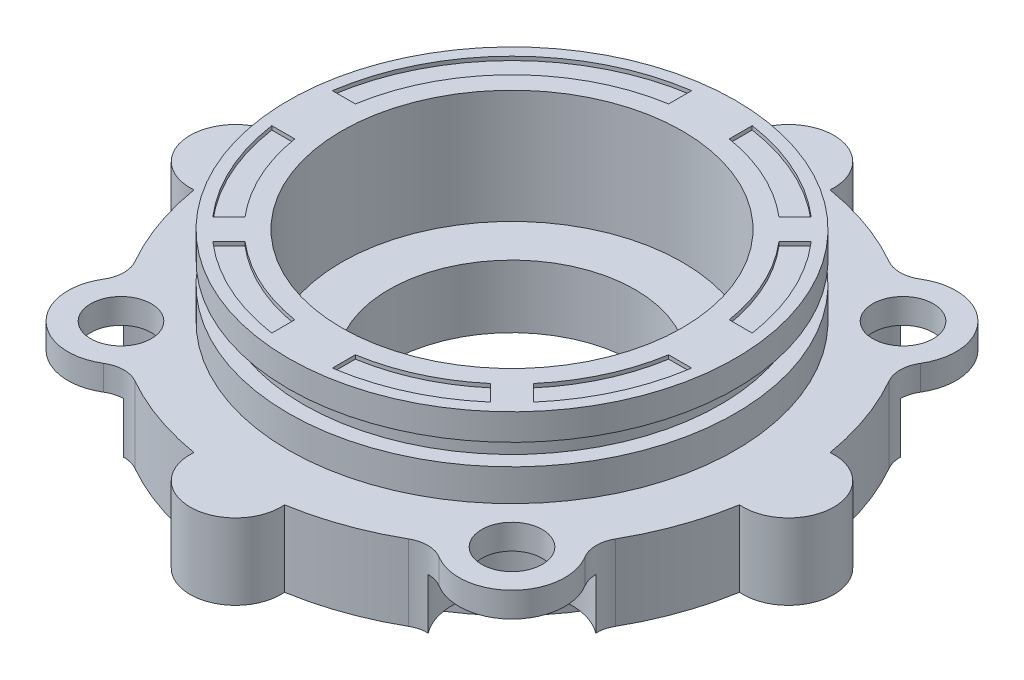
from build123d import *

# Parameters (mm, degrees)
CUT_EXTRUDE2_DEPTH = 65.844043674
SKETCH4_R          = 4
CUT_EXTRUDE3_DEPTH = 6.7
SKETCH5_R          = 4
CUT_EXTRUDE4_DEPTH = 36.7
CIRPATTERN1_COUNT  = 4
CUT_EXTRUDE5_START = -0.5
SKETCH6_R          = 22.5
CUT_EXTRUDE5_DEPTH = 0.5


with BuildPart() as part:
    # Sketch1 → Revolve1 (revolve)
    with BuildSketch(Plane.XY):
        Polygon((16.25, -33.807578124), (29.5, -33.807578124), (29.5, -31.007578124), (43.5, -31.007578124), (43.5, -21.007578124), (29.5, -21.007578124), (29.5, -16.800812474), (27.5, -16.800812474), (27.5, -14.000812474), (29.5, -14.000812474), (29.5, -10.507578124), (22.5, -10.507578124), (22.5, -25.507578124), (16.25, -25.507578124), align=None)
    revolve(axis=Axis((0, 0, 0), (0, -1, 0)))

    # Sketch2 → Cut-Extrude2 (cut, through all)
    with BuildSketch(Plane.XZ.offset(31.007578124)):
        with BuildLine():
            ThreePointArc((-18.075547766, 31.710007458), (-12.217996522, 34.394339083), (-5.97969919, 36.006849315))
            ThreePointArc((-5.97969919, 36.006849315), (0, 42.5), (5.97969919, 36.006849315))
            ThreePointArc((5.97969919, 36.006849315), (12.217996522, 34.394339083), (18.075547766, 31.710007458))
            ThreePointArc((18.075547766, 31.710007458), (20.120976666, 31.185597591), (22.148418004, 31.775738857))
            ThreePointArc((22.148418004, 31.775738857), (26.630126737, 32.76111698), (30.759144954, 30.759145009))
            ThreePointArc((30.759144954, 30.759145009), (-2.4e-08, 43.5), (-30.759144987, 30.759144976))
            ThreePointArc((-30.759144987, 30.759144976), (-26.63012676, 32.761116977), (-22.148418004, 31.775738857))
            ThreePointArc((-22.148418004, 31.775738857), (-20.120976666, 31.185597591), (-18.075547766, 31.710007458))
        make_face()
        with BuildLine():
            ThreePointArc((-31.775738857, 22.148418004), (-32.761116978, 26.630126752), (-30.759144987, 30.759144976))
            ThreePointArc((-30.759144987, 30.759144976), (-43.5, -2.1e-08), (-30.759144958, -30.759145005))
            ThreePointArc((-30.759144958, -30.759145005), (-32.761116976, -26.630126773), (-31.775738857, -22.148418004))
            ThreePointArc((-31.775738857, -22.148418004), (-31.185597591, -20.120976666), (-31.710007458, -18.075547766))
            ThreePointArc((-31.710007458, -18.075547766), (-34.394339083, -12.217996522), (-36.006849315, -5.97969919))
            ThreePointArc((-36.006849315, -5.97969919), (-42.5, 0), (-36.006849315, 5.97969919))
            ThreePointArc((-36.006849315, 5.97969919), (-34.394339083, 12.217996522), (-31.710007458, 18.075547766))
            ThreePointArc((-31.710007458, 18.075547766), (-31.185597591, 20.120976666), (-31.775738857, 22.148418004))
        make_face()
        with BuildLine():
            ThreePointArc((30.759144986, -30.759144977), (43.5, 2.3e-08), (30.759144954, 30.759145009))
            ThreePointArc((30.759144954, 30.759145009), (32.761116975, 26.630126776), (31.775738857, 22.148418004))
            ThreePointArc((31.775738857, 22.148418004), (31.185597591, 20.120976666), (31.710007458, 18.075547766))
            ThreePointArc((31.710007458, 18.075547766), (34.394339083, 12.217996522), (36.006849315, 5.97969919))
            ThreePointArc((36.006849315, 5.97969919), (42.5, 0), (36.006849315, -5.97969919))
            ThreePointArc((36.006849315, -5.97969919), (34.394339083, -12.217996522), (31.710007458, -18.075547766))
            ThreePointArc((31.710007458, -18.075547766), (31.185597591, -20.120976666), (31.775738857, -22.148418004))
            ThreePointArc((31.775738857, -22.148418004), (32.761116978, -26.630126753), (30.759144986, -30.759144977))
        make_face()
        with BuildLine():
            ThreePointArc((-22.148418004, -31.775738857), (-26.630126739, -32.76111698), (-30.759144958, -30.759145005))
            ThreePointArc((-30.759144958, -30.759145005), (2e-08, -43.5), (30.759144986, -30.759144977))
            ThreePointArc((30.759144986, -30.759144977), (26.630126759, -32.761116977), (22.148418004, -31.775738857))
            ThreePointArc((22.148418004, -31.775738857), (20.120976666, -31.185597591), (18.075547766, -31.710007458))
            ThreePointArc((18.075547766, -31.710007458), (12.217996522, -34.394339083), (5.97969919, -36.006849315))
            ThreePointArc((5.97969919, -36.006849315), (0, -42.5), (-5.97969919, -36.006849315))
            ThreePointArc((-5.97969919, -36.006849315), (-12.217996522, -34.394339083), (-18.075547766, -31.710007458))
            ThreePointArc((-18.075547766, -31.710007458), (-20.120976666, -31.185597591), (-22.148418004, -31.775738857))
        make_face()
    extrude(amount=-CUT_EXTRUDE2_DEPTH, mode=Mode.SUBTRACT)

    # Sketch4 → Cut-Extrude3 (cut)
    with BuildSketch(Plane.XZ.offset(31.007578124)):
        with BuildLine():
            ThreePointArc((20.120976666, 31.185597591), (18.564665358, 25.884871335), (20.859650045, 20.859650045))
            ThreePointArc((20.859650045, 20.859650045), (25.884871335, 18.564665358), (31.185597591, 20.120976666))
            ThreePointArc((31.185597591, 20.120976666), (31.344468449, 21.174341938), (31.775738857, 22.148418004))
            ThreePointArc((31.775738857, 22.148418004), (30.759144982, 30.759144982), (22.148418004, 31.775738857))
            ThreePointArc((22.148418004, 31.775738857), (21.174341938, 31.344468449), (20.120976666, 31.185597591))
        make_face()
        with Locations((25.809397513, 25.809397513)):
            Circle(SKETCH4_R, mode=Mode.SUBTRACT)
    cut_extrude3 = extrude(amount=-CUT_EXTRUDE3_DEPTH, mode=Mode.SUBTRACT)

    # Sketch5 → Cut-Extrude4 (cut)
    with BuildSketch(Plane.XZ.offset(31.007578124)):
        with Locations((25.809397513, 25.809397513)):
            Circle(SKETCH5_R)
    cut_extrude4 = extrude(amount=-CUT_EXTRUDE4_DEPTH, mode=Mode.SUBTRACT)

    # CirPattern1: Cut-Extrude3, Cut-Extrude4 ×4 about axis
    cirpattern1_axis = Axis((0, -31.007578124, 0), (0, -1, 0))
    add([cut_extrude3.rotate(cirpattern1_axis, i * 360 / CIRPATTERN1_COUNT) for i in range(1, CIRPATTERN1_COUNT)], mode=Mode.SUBTRACT)
    add([cut_extrude4.rotate(cirpattern1_axis, i * 360 / CIRPATTERN1_COUNT) for i in range(1, CIRPATTERN1_COUNT)], mode=Mode.SUBTRACT)

    # Sketch6 → Cut-Extrude5 (cut)
    with BuildSketch(Plane(origin=(0, -10.507578124, 0), x_dir=(1, 0, 0), z_dir=(0, 1, 0)).offset(CUT_EXTRUDE5_START)):
        with BuildLine():
            Line((21.162631221, 18.334204096), (19.035223749, 16.206796624))
            ThreePointArc((19.035223749, 16.206796624), (22.692759246, 10.489932212), (24.677925359, 4))
            Line((24.677925359, 4), (27.712812921, 4))
            ThreePointArc((27.712812921, 4), (25.467029897, 11.637456261), (21.162631221, 18.334204096))
        make_face()
        with BuildLine():
            ThreePointArc((4, 24.677925359), (10.489932212, 22.692759246), (16.206796624, 19.035223749))
            Line((16.206796624, 19.035223749), (18.334204096, 21.162631221))
            ThreePointArc((18.334204096, 21.162631221), (11.637456261, 25.467029897), (4, 27.712812921))
            Line((4, 27.712812921), (4, 24.677925359))
        make_face()
        with BuildLine():
            Line((19.035223749, -16.206796624), (21.162631221, -18.334204096))
            ThreePointArc((21.162631221, -18.334204096), (25.467029897, -11.637456261), (27.712812921, -4))
            Line((27.712812921, -4), (24.677925359, -4))
            ThreePointArc((24.677925359, -4), (22.692759246, -10.489932212), (19.035223749, -16.206796624))
        make_face()
        with BuildLine():
            Line((18.334204096, -21.162631221), (16.206796624, -19.035223749))
            ThreePointArc((16.206796624, -19.035223749), (10.489932212, -22.692759246), (4, -24.677925359))
            Line((4, -24.677925359), (4, -27.712812921))
            ThreePointArc((4, -27.712812921), (11.637456261, -25.467029897), (18.334204096, -21.162631221))
        make_face()
        with BuildLine():
            Line((-4, 24.677925359), (-4, 27.712812921))
            ThreePointArc((-4, 27.712812921), (-19.798989873, 19.798989873), (-27.712812921, 4))
            Line((-27.712812921, 4), (-24.677925359, 4))
            ThreePointArc((-24.677925359, 4), (-17.67766953, 17.67766953), (-4, 24.677925359))
        make_face()
        with BuildLine():
            Line((-24.677925359, -4), (-27.712812921, -4))
            ThreePointArc((-27.712812921, -4), (-25.467029897, -11.637456261), (-21.162631221, -18.334204096))
            Line((-21.162631221, -18.334204096), (-19.035223749, -16.206796624))
            ThreePointArc((-19.035223749, -16.206796624), (-22.692759246, -10.489932212), (-24.677925359, -4))
        make_face()
        with BuildLine():
            Line((-16.206796624, -19.035223749), (-18.334204096, -21.162631221))
            ThreePointArc((-18.334204096, -21.162631221), (-11.637456261, -25.467029897), (-4, -27.712812921))
            Line((-4, -27.712812921), (-4, -24.677925359))
            ThreePointArc((-4, -24.677925359), (-10.489932212, -22.692759246), (-16.206796624, -19.035223749))
        make_face()
        Circle(SKETCH6_R)
    extrude(amount=CUT_EXTRUDE5_DEPTH, mode=Mode.SUBTRACT)


solid = part.part
